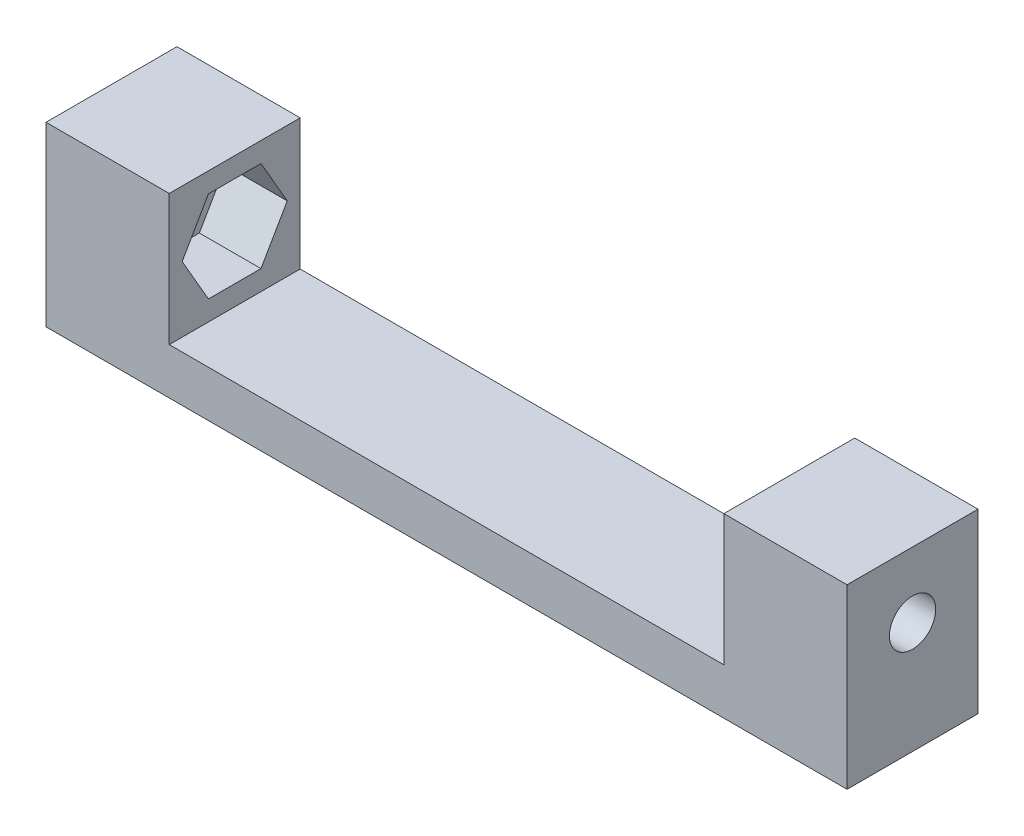
from build123d import *

# Parameters (mm, degrees)
SKETCH1_W           = 8.5
SKETCH1_H           = 8.5
BOSS_EXTRUDE1_DEPTH = 5
SKETCH2_W           = 8.5
SKETCH2_H           = 8.5
BOSS_EXTRUDE2_DEPTH = 2
SKETCH3_R           = 1.5
CUT_EXTRUDE1_DEPTH  = 2
SKETCH4_W           = 52
SKETCH4_H           = 8.5
BOSS_EXTRUDE3_DEPTH = 3
SKETCH5_W           = 7
SKETCH5_H           = 8.5
BOSS_EXTRUDE4_DEPTH = 8.5
CUT_EXTRUDE2_DEPTH  = 5
SKETCH7_R           = 1.5
CUT_EXTRUDE3_DEPTH  = 5
SKETCH8_R           = 1.5
BOSS_EXTRUDE5_DEPTH = 2.5
SKETCH9_R           = 1.5
BOSS_EXTRUDE6_DEPTH = 2.5
SKETCH10_W          = 8.5
SKETCH10_H          = 8.5
BOSS_EXTRUDE7_DEPTH = 1
SKETCH11_W          = 8.5
SKETCH11_H          = 8.5
BOSS_EXTRUDE8_DEPTH = 1
CUT_EXTRUDE4_DEPTH  = 0.5
CUT_EXTRUDE5_DEPTH  = 0.5


with BuildPart() as part:
    # Sketch1 → Boss-Extrude1 (new body)
    with BuildSketch(Plane(origin=(0, 0, 0), x_dir=(0, 0, -1), z_dir=(1, 0, 0))):
        Rectangle(SKETCH1_W, SKETCH1_H)
        Polygon((1.705, 2.953146627), (-1.705, 2.953146627), (-3.41, 0), (-1.705, -2.953146627), (1.705, -2.953146627), (3.41, 0), align=None, mode=Mode.SUBTRACT)
    extrude(amount=BOSS_EXTRUDE1_DEPTH)

    # Sketch2 → Boss-Extrude2 (add)
    with BuildSketch(Plane.ZY):
        Rectangle(SKETCH2_W, SKETCH2_H)
    extrude(amount=BOSS_EXTRUDE2_DEPTH)

    # Sketch3 → Cut-Extrude1 (cut)
    with BuildSketch(Plane(origin=(0, 0, 0), x_dir=(0, 0, -1), z_dir=(1, 0, 0))):
        Circle(SKETCH3_R)
    extrude(amount=-CUT_EXTRUDE1_DEPTH, mode=Mode.SUBTRACT)

    # Sketch4 → Boss-Extrude3 (add)
    with BuildSketch(Plane.XZ.offset(4.25)):
        with Locations((24, 0)):
            Rectangle(SKETCH4_W, SKETCH4_H)
    extrude(amount=BOSS_EXTRUDE3_DEPTH)

    # Sketch5 → Boss-Extrude4 (add)
    with BuildSketch(Plane(origin=(0, -4.25, 0), x_dir=(1, 0, 0), z_dir=(0, 1, 0))):
        with Locations((46.5, 0)):
            Rectangle(SKETCH5_W, SKETCH5_H)
    extrude(amount=BOSS_EXTRUDE4_DEPTH)

    # Sketch6 → Cut-Extrude2 (cut)
    with BuildSketch(Plane.ZY.offset(-43)):
        Polygon((3.41, 0), (1.705, 2.953146627), (-1.705, 2.953146627), (-3.41, 0), (-1.705, -2.953146627), (1.705, -2.953146627), align=None)
    extrude(amount=-CUT_EXTRUDE2_DEPTH, mode=Mode.SUBTRACT)

    # Sketch7 → Cut-Extrude3 (cut)
    with BuildSketch(Plane.ZY.offset(-48)):
        Circle(SKETCH7_R)
    extrude(amount=-CUT_EXTRUDE3_DEPTH, mode=Mode.SUBTRACT)

    # Sketch8 → Boss-Extrude5 (add)
    with BuildSketch(Plane(origin=(0, 0, 0), x_dir=(0, 0, -1), z_dir=(1, 0, 0))):
        Polygon((-1.705, 2.953146627), (-3.41, 0), (-1.705, -2.953146627), (1.705, -2.953146627), (3.41, 0), (1.705, 2.953146627), align=None)
        Circle(SKETCH8_R, mode=Mode.SUBTRACT)
    extrude(amount=BOSS_EXTRUDE5_DEPTH)

    # Sketch9 → Boss-Extrude6 (add)
    with BuildSketch(Plane.ZY.offset(-48)):
        Polygon((3.41, 0), (1.705, 2.953146627), (-1.705, 2.953146627), (-3.41, 0), (-1.705, -2.953146627), (1.705, -2.953146627), align=None)
        Circle(SKETCH9_R, mode=Mode.SUBTRACT)
    extrude(amount=BOSS_EXTRUDE6_DEPTH)

    # Sketch10 → Boss-Extrude7 (add)
    with BuildSketch(Plane(origin=(5, 0, 0), x_dir=(0, 0, -1), z_dir=(1, 0, 0))):
        Rectangle(SKETCH10_W, SKETCH10_H)
        Polygon((3.41, 0), (1.705, 2.953146627), (-1.705, 2.953146627), (-3.41, 0), (-1.705, -2.953146627), (1.705, -2.953146627), align=None, mode=Mode.SUBTRACT)
    extrude(amount=BOSS_EXTRUDE7_DEPTH)

    # Sketch11 → Boss-Extrude8 (add)
    with BuildSketch(Plane.ZY.offset(-43)):
        Rectangle(SKETCH11_W, SKETCH11_H)
        Polygon((-3.41, 0), (-1.705, -2.953146627), (1.705, -2.953146627), (3.41, 0), (1.705, 2.953146627), (-1.705, 2.953146627), align=None, mode=Mode.SUBTRACT)
    extrude(amount=BOSS_EXTRUDE8_DEPTH)

    # Sketch12 → Cut-Extrude4 (cut)
    with BuildSketch(Plane(origin=(2.5, 0, 0), x_dir=(0, 0, -1), z_dir=(1, 0, 0))):
        Polygon((1.705, -2.953146627), (3.41, 0), (1.705, 2.953146627), (-1.705, 2.953146627), (-3.41, 0), (-1.705, -2.953146627), align=None)
    extrude(amount=-CUT_EXTRUDE4_DEPTH, mode=Mode.SUBTRACT)

    # Sketch13 → Cut-Extrude5 (cut)
    with BuildSketch(Plane.ZY.offset(-45.5)):
        Polygon((1.705, 2.953146627), (-1.705, 2.953146627), (-3.41, 0), (-1.705, -2.953146627), (1.705, -2.953146627), (3.41, 0), align=None)
    extrude(amount=-CUT_EXTRUDE5_DEPTH, mode=Mode.SUBTRACT)


solid = part.part
